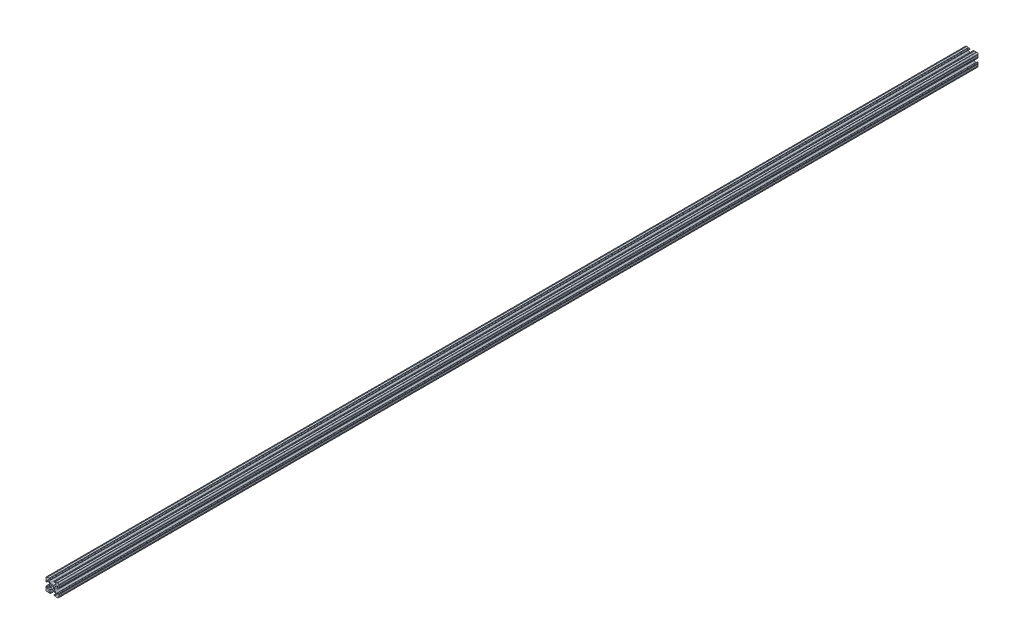
from build123d import *

# Parameters (mm, degrees)
SKETCH1_R               = 2.6035
BOSS_EXTRUDE1_DEPTH     = 914.4
SKETCH2_R               = 3.175
CUT_EXTRUDE1_DEPTH      = 9.1915
CUT_EXTRUDE1_DEPTH_BACK = 18.2085


with BuildPart() as part:
    # Sketch1 → Boss-Extrude1 (new body, symmetric)
    with BuildSketch(Plane.XY):
        with BuildLine():
            Line((-7.179650497, -8.645192506), (-3.952270251, -5.423690499))
            ThreePointArc((-3.952270251, -5.423690499), (-2.922936451, -4.736929036), (-1.709253557, -4.4958))
            Line((-1.709253557, -4.4958), (1.709253557, -4.4958))
            ThreePointArc((1.709253557, -4.4958), (2.922936451, -4.736929036), (3.952270251, -5.423690499))
            Line((3.952270251, -5.423690499), (7.179650497, -8.645192506))
            ThreePointArc((7.179650497, -8.645192506), (7.41473083, -9.822813117), (6.416408329, -10.4902))
            Line((6.416408329, -10.4902), (4.287512407, -10.4902))
            ThreePointArc((4.287512407, -10.4902), (3.54574862, -10.79744862), (3.2385, -11.539212407))
            Line((3.2385, -11.539212407), (3.2385, -11.650987593))
            ThreePointArc((3.2385, -11.650987593), (3.54574862, -12.39275138), (4.287512407, -12.7))
            Line((4.287512407, -12.7), (5.317126718, -12.7))
            ThreePointArc((5.317126718, -12.7), (5.825126718, -12.192), (6.333126718, -12.7))
            Line((6.333126718, -12.7), (9.550443118, -12.7))
            ThreePointArc((9.550443118, -12.7), (10.058366869, -12.192000006), (10.566443095, -12.699847501))
            ThreePointArc((10.566443095, -12.699847501), (12.082537762, -12.08250727), (12.699846982, -10.566399977))
            ThreePointArc((12.699846982, -10.566399977), (12.192000006, -10.058323491), (12.7, -9.5504))
            Line((12.7, -9.5504), (12.7, -6.3330836))
            ThreePointArc((12.7, -6.3330836), (12.192, -5.8250836), (12.7, -5.3170836))
            Line((12.7, -5.3170836), (12.7, -4.287469289))
            ThreePointArc((12.7, -4.287469289), (12.39275138, -3.545705502), (11.650987593, -3.238456882))
            Line((11.650987593, -3.238456882), (11.539212407, -3.238456882))
            ThreePointArc((11.539212407, -3.238456882), (10.79744862, -3.545705502), (10.4902, -4.287469289))
            Line((10.4902, -4.287469289), (10.4902, -6.402089023))
            ThreePointArc((10.4902, -6.402089023), (9.856505071, -7.351067942), (8.737131347, -7.129408934))
            Line((8.737131347, -7.129408934), (5.441005833, -3.840816462))
            ThreePointArc((5.441005833, -3.840816462), (4.750877967, -2.809883091), (4.5085, -1.593185507))
            Line((4.5085, -1.593185507), (4.5085, 1.593185507))
            ThreePointArc((4.5085, 1.593185507), (4.750877967, 2.809883091), (5.441005833, 3.840816462))
            Line((5.441005833, 3.840816462), (8.737131347, 7.129408934))
            ThreePointArc((8.737131347, 7.129408934), (9.856505071, 7.351067942), (10.4902, 6.402089023))
            Line((10.4902, 6.402089023), (10.4902, 4.287469289))
            ThreePointArc((10.4902, 4.287469289), (10.79744862, 3.545705502), (11.539212407, 3.238456882))
            Line((11.539212407, 3.238456882), (11.650987593, 3.238456882))
            ThreePointArc((11.650987593, 3.238456882), (12.39275138, 3.545705502), (12.7, 4.287469289))
            Line((12.7, 4.287469289), (12.7, 5.3170836))
            ThreePointArc((12.7, 5.3170836), (12.192, 5.8250836), (12.7, 6.3330836))
            Line((12.7, 6.3330836), (12.7, 9.5504))
            ThreePointArc((12.7, 9.5504), (12.192000006, 10.058323491), (12.699846982, 10.566399977))
            ThreePointArc((12.699846982, 10.566399977), (12.082537762, 12.08250727), (10.566443095, 12.699847501))
            ThreePointArc((10.566443095, 12.699847501), (10.058366869, 12.192000006), (9.550443118, 12.7))
            Line((9.550443118, 12.7), (6.333126718, 12.7))
            ThreePointArc((6.333126718, 12.7), (5.825126718, 12.192), (5.317126718, 12.7))
            Line((5.317126718, 12.7), (4.287512407, 12.7))
            ThreePointArc((4.287512407, 12.7), (3.54574862, 12.39275138), (3.2385, 11.650987593))
            Line((3.2385, 11.650987593), (3.2385, 11.539212407))
            ThreePointArc((3.2385, 11.539212407), (3.54574862, 10.79744862), (4.287512407, 10.4902))
            Line((4.287512407, 10.4902), (6.476788598, 10.4902))
            ThreePointArc((6.476788598, 10.4902), (7.432222385, 9.85140422), (7.207036008, 8.724370562))
            Line((7.207036008, 8.724370562), (3.898272566, 5.423169045))
            ThreePointArc((3.898272566, 5.423169045), (2.869120213, 4.736787962), (1.655778399, 4.4958))
            Line((1.655778399, 4.4958), (-1.655778399, 4.4958))
            ThreePointArc((-1.655778399, 4.4958), (-2.869120213, 4.736787962), (-3.898272566, 5.423169045))
            Line((-3.898272566, 5.423169045), (-7.207036008, 8.724370562))
            ThreePointArc((-7.207036008, 8.724370562), (-7.432222385, 9.85140422), (-6.476788598, 10.4902))
            Line((-6.476788598, 10.4902), (-4.287512407, 10.4902))
            ThreePointArc((-4.287512407, 10.4902), (-3.54574862, 10.79744862), (-3.2385, 11.539212407))
            Line((-3.2385, 11.539212407), (-3.2385, 11.650987593))
            ThreePointArc((-3.2385, 11.650987593), (-3.54574862, 12.39275138), (-4.287512407, 12.7))
            Line((-4.287512407, 12.7), (-5.317126718, 12.7))
            ThreePointArc((-5.317126718, 12.7), (-5.825126718, 12.192), (-6.333126718, 12.7))
            Line((-6.333126718, 12.7), (-9.550443118, 12.7))
            ThreePointArc((-9.550443118, 12.7), (-10.058366869, 12.192000006), (-10.566443095, 12.699847501))
            ThreePointArc((-10.566443095, 12.699847501), (-12.082537762, 12.08250727), (-12.699846982, 10.566399977))
            ThreePointArc((-12.699846982, 10.566399977), (-12.192000006, 10.058323491), (-12.7, 9.5504))
            Line((-12.7, 9.5504), (-12.7, 6.3330836))
            ThreePointArc((-12.7, 6.3330836), (-12.192, 5.8250836), (-12.7, 5.3170836))
            Line((-12.7, 5.3170836), (-12.7, 4.287469289))
            ThreePointArc((-12.7, 4.287469289), (-12.39275138, 3.545705502), (-11.650987593, 3.238456882))
            Line((-11.650987593, 3.238456882), (-11.539212407, 3.238456882))
            ThreePointArc((-11.539212407, 3.238456882), (-10.79744862, 3.545705502), (-10.4902, 4.287469289))
            Line((-10.4902, 4.287469289), (-10.4902, 6.402089023))
            ThreePointArc((-10.4902, 6.402089023), (-9.856505071, 7.351067942), (-8.737131347, 7.129408934))
            Line((-8.737131347, 7.129408934), (-5.441005833, 3.840816462))
            ThreePointArc((-5.441005833, 3.840816462), (-4.750877967, 2.809883091), (-4.5085, 1.593185507))
            Line((-4.5085, 1.593185507), (-4.5085, -1.593185507))
            ThreePointArc((-4.5085, -1.593185507), (-4.750877967, -2.809883091), (-5.441005833, -3.840816462))
            Line((-5.441005833, -3.840816462), (-8.737131347, -7.129408934))
            ThreePointArc((-8.737131347, -7.129408934), (-9.856505071, -7.351067942), (-10.4902, -6.402089023))
            Line((-10.4902, -6.402089023), (-10.4902, -4.287469289))
            ThreePointArc((-10.4902, -4.287469289), (-10.79744862, -3.545705502), (-11.539212407, -3.238456882))
            Line((-11.539212407, -3.238456882), (-11.650987593, -3.238456882))
            ThreePointArc((-11.650987593, -3.238456882), (-12.39275138, -3.545705502), (-12.7, -4.287469289))
            Line((-12.7, -4.287469289), (-12.7, -5.3170836))
            ThreePointArc((-12.7, -5.3170836), (-12.192, -5.8250836), (-12.7, -6.3330836))
            Line((-12.7, -6.3330836), (-12.7, -9.5504))
            ThreePointArc((-12.7, -9.5504), (-12.192000006, -10.058323491), (-12.699846982, -10.566399977))
            ThreePointArc((-12.699846982, -10.566399977), (-12.082537762, -12.08250727), (-10.566443095, -12.699847501))
            ThreePointArc((-10.566443095, -12.699847501), (-10.058366869, -12.192000006), (-9.550443118, -12.7))
            Line((-9.550443118, -12.7), (-6.333126718, -12.7))
            ThreePointArc((-6.333126718, -12.7), (-5.825126718, -12.192), (-5.317126718, -12.7))
            Line((-5.317126718, -12.7), (-4.287512407, -12.7))
            ThreePointArc((-4.287512407, -12.7), (-3.54574862, -12.39275138), (-3.2385, -11.650987593))
            Line((-3.2385, -11.650987593), (-3.2385, -11.539212407))
            ThreePointArc((-3.2385, -11.539212407), (-3.54574862, -10.79744862), (-4.287512407, -10.4902))
            Line((-4.287512407, -10.4902), (-6.416408329, -10.4902))
            ThreePointArc((-6.416408329, -10.4902), (-7.41473083, -9.822813117), (-7.179650497, -8.645192506))
        make_face()
        Circle(SKETCH1_R, mode=Mode.SUBTRACT)
    extrude(amount=BOSS_EXTRUDE1_DEPTH, both=True)

    # Sketch2 → Cut-Extrude1 (cut, two sides)
    with BuildSketch(Plane(origin=(4.5085, 0, 0), x_dir=(0, 0, -1), z_dir=(1, 0, 0))) as cut_extrude1_sk:
        Circle(SKETCH2_R)
    extrude(amount=CUT_EXTRUDE1_DEPTH, mode=Mode.SUBTRACT)
    extrude(cut_extrude1_sk.sketch, amount=-CUT_EXTRUDE1_DEPTH_BACK, mode=Mode.SUBTRACT)


solid = part.part
